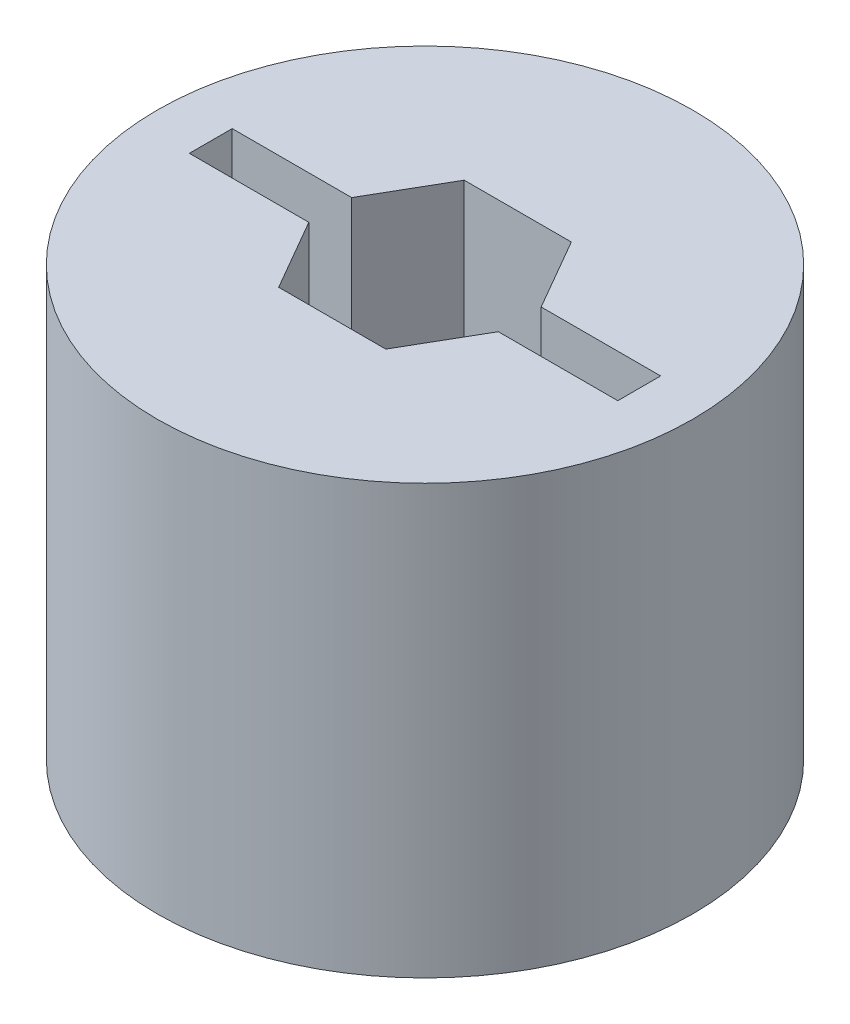
from build123d import *

# Parameters (mm, degrees)
SKETCH1_R           = 15.875
BOSS_EXTRUDE1_DEPTH = 25.4
CUT_EXTRUDE1_DEPTH  = 26.4


with BuildPart() as part:
    # Sketch1 → Boss-Extrude1 (new body)
    with BuildSketch(Plane(origin=(0, 0, 0), x_dir=(1, 0, 0), z_dir=(0, 1, 0))):
        Circle(SKETCH1_R)
    extrude(amount=BOSS_EXTRUDE1_DEPTH)

    # Sketch2 → Cut-Extrude1 (cut, through all)
    with BuildSketch(Plane(origin=(0, 25.4, 0), x_dir=(1, 0, 0), z_dir=(0, 1, 0))):
        Polygon((-6.35, 0), (-5.616765158, 1.27), (-12.7, 1.27), (-12.7, -1.27), (-5.616765158, -1.27), align=None)
        Polygon((3.175, -5.499261314), (5.616765158, -1.27), (-5.616765158, -1.27), (-3.175, -5.499261314), align=None)
        Polygon((6.35, 0), (5.616765158, 1.27), (-5.616765158, 1.27), (-6.35, 0), (-5.616765158, -1.27), (5.616765158, -1.27), align=None)
        Polygon((5.616765158, 1.27), (3.175, 5.499261314), (-3.175, 5.499261314), (-5.616765158, 1.27), align=None)
        Polygon((12.7, 1.27), (5.616765158, 1.27), (6.35, 0), (5.616765158, -1.27), (12.7, -1.27), align=None)
    extrude(amount=-CUT_EXTRUDE1_DEPTH, mode=Mode.SUBTRACT)


solid = part.part
